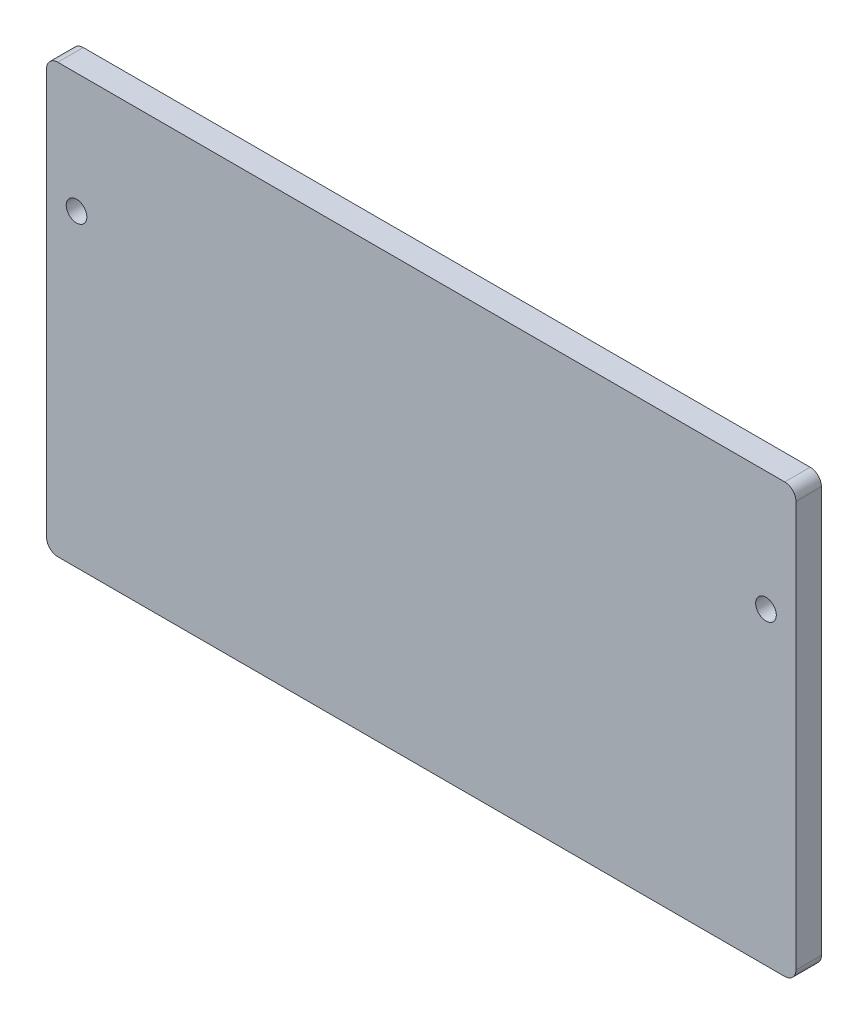
from build123d import *

# Parameters (mm, degrees)
SKETCH1_W            = 200
SKETCH1_H            = 114.3
BOSS_EXTRUDE1_DEPTH  = 6.8
SKETCH2_R            = 2.75
CUT_EXTRUDE1_DEPTH   = 6.8
FILLET1_R            = 3
FILLET1_OF_MIRROR2_R = 3


with BuildPart() as part:
    # Sketch1 → Boss-Extrude1 (new body)
    with BuildSketch(Plane.XY):
        Rectangle(SKETCH1_W, SKETCH1_H)
    extrude(amount=BOSS_EXTRUDE1_DEPTH)

    # Sketch2 → Cut-Extrude1 (cut)
    with BuildSketch(Plane.XY.offset(6.8)):
        with Locations((-92, 25.25)):
            Circle(SKETCH2_R)
    cut_extrude1 = extrude(amount=-CUT_EXTRUDE1_DEPTH, mode=Mode.SUBTRACT)

    # Fillet1
    fillet1_edges = [part.edges().sort_by_distance(p)[0] for p in [
        (-100, 57.15, 3.4),
        (-100, -57.15, 3.4),
    ]]
    fillet(fillet1_edges, radius=FILLET1_R)

    # Mirror2: Cut-Extrude1 across plane
    add(cut_extrude1.mirror(Plane(origin=(0, 0, 0), x_dir=(0, 0, 1), z_dir=(1, 0, 0))), mode=Mode.SUBTRACT)

    # Fillet1 of Mirror2
    fillet1_of_mirror2_edges = [part.edges().sort_by_distance(p)[0] for p in [
        (100, 57.15, 3.4),
        (100, -57.15, 3.4),
    ]]
    fillet(fillet1_of_mirror2_edges, radius=FILLET1_OF_MIRROR2_R)


solid = part.part
